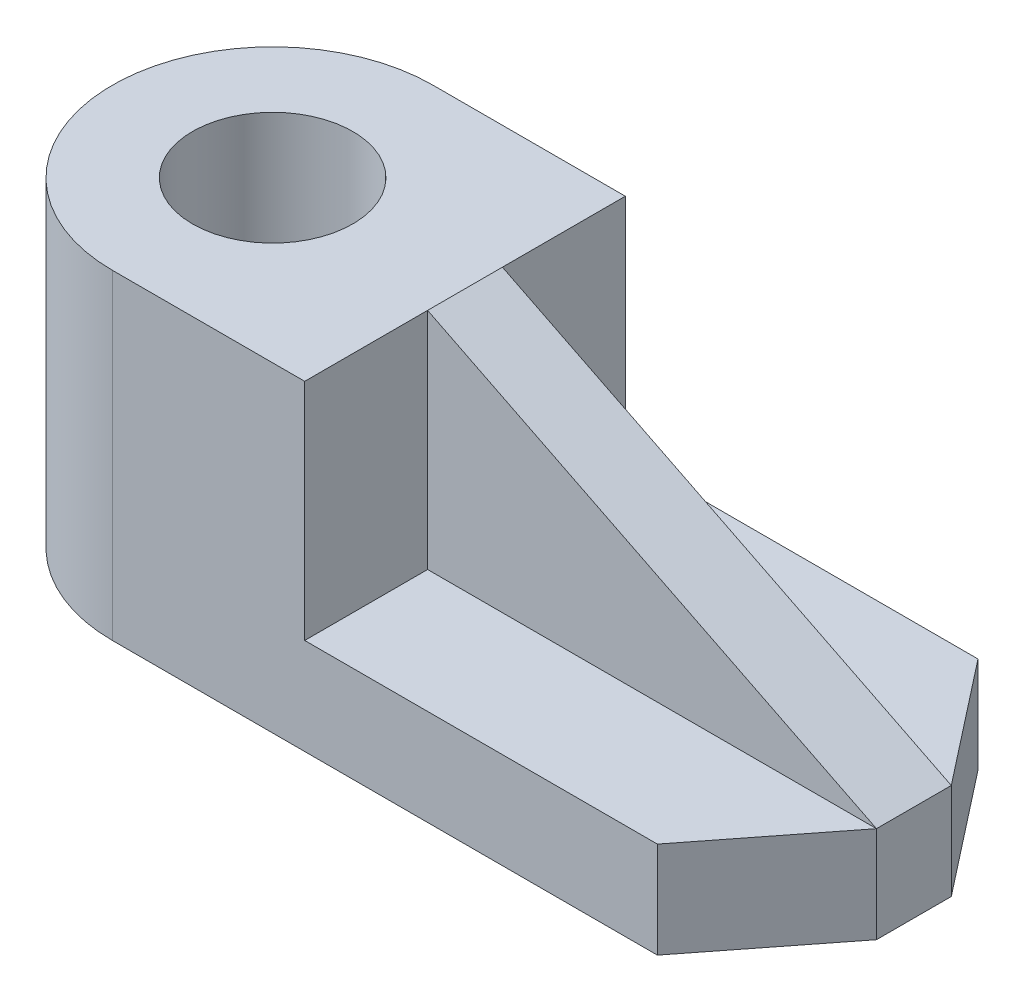
from build123d import *

# Parameters (mm, degrees)
CROQUIS5_R                   = 7.5
SALIENTE_EXTRUIR3_DEPTH      = 30
SALIENTE_EXTRUIR4_DEPTH      = 9
SALIENTE_EXTRUIR5_DEPTH      = 3.5
SALIENTE_EXTRUIR5_DEPTH_BACK = 3.5


with BuildPart() as part:
    # Croquis5 → Saliente-Extruir3 (new body)
    with BuildSketch(Plane(origin=(0, 0, 0), x_dir=(1, 0, 0), z_dir=(0, 1, 0))):
        with BuildLine():
            Line((0, 15), (18, 15))
            Line((18, 15), (18, -15))
            Line((18, -15), (0, -15))
            ThreePointArc((0, -15), (-15, 0), (0, 15))
        make_face()
        Circle(CROQUIS5_R, mode=Mode.SUBTRACT)
    extrude(amount=SALIENTE_EXTRUIR3_DEPTH)

    # Croquis6 → Saliente-Extruir4 (add)
    with BuildSketch(Plane(origin=(0, 0, 0), x_dir=(1, 0, 0), z_dir=(0, 1, 0))):
        Polygon((18, 15), (18, -15), (51, -15), (60, -3.5), (60, 3.5), (51, 15), align=None)
    extrude(amount=SALIENTE_EXTRUIR4_DEPTH)

    # Croquis8 → Saliente-Extruir5 (add, two sides)
    with BuildSketch(Plane.XY) as saliente_extruir5_sk:
        Polygon((18, 30), (60, 9), (18, 9), align=None)
    extrude(amount=SALIENTE_EXTRUIR5_DEPTH)
    extrude(saliente_extruir5_sk.sketch, amount=-SALIENTE_EXTRUIR5_DEPTH_BACK)


solid = part.part
